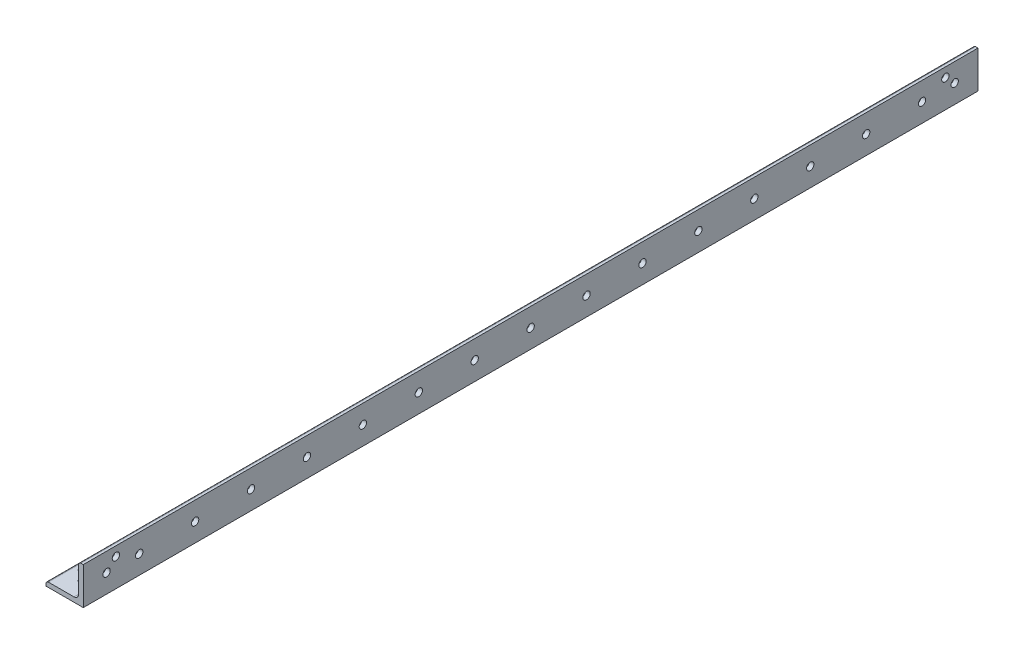
from build123d import *

# Parameters (mm, degrees)
BOSS_EXTRUDE1_DEPTH = 304.8
SKETCH3_R           = 2.5
CUT_EXTRUDE2_DEPTH  = 254
SKETCH8_R           = 2.5
CUT_EXTRUDE4_DEPTH  = 254
SKETCH9_R           = 2.25
CUT_EXTRUDE5_DEPTH  = 25.4


with BuildPart() as part:
    # Sketch2 → Boss-Extrude1 (new, symmetric)
    with BuildSketch(Plane.XY):
        with BuildLine():
            Line((-12.7, -12.7), (12.7, -12.7))
            Line((12.7, -12.7), (12.7, 12.7))
            Line((12.7, 12.7), (11.1125, 12.7))
            ThreePointArc((11.1125, 12.7), (9.989967985, 12.235032015), (9.525, 11.1125))
            Line((9.525, 11.1125), (9.525, -6.35))
            ThreePointArc((9.525, -6.35), (8.59506403, -8.59506403), (6.35, -9.525))
            Line((6.35, -9.525), (-11.1125, -9.525))
            ThreePointArc((-11.1125, -9.525), (-12.235032015, -9.989967985), (-12.7, -11.1125))
            Line((-12.7, -11.1125), (-12.7, -12.7))
        make_face()
    extrude(amount=BOSS_EXTRUDE1_DEPTH, both=True)

    # Sketch3 → Cut-Extrude2 (cut)
    with BuildSketch(Plane(origin=(0, 0, 0), x_dir=(1, 0, 0), z_dir=(0, 1, 0))):
        with Locations(Location((-6.35, 285.75, 0), (0, 0, 270))):
            Circle(SKETCH3_R)
        with Locations(Location((0, 292.1, 0), (0, 0, 270))):
            Circle(SKETCH3_R)
        with Locations(Location((0, 266.7, 0), (0, 0, 270))):
            Circle(SKETCH3_R)
        with Locations(Location((0, 228.6, 0), (0, 0, 270))):
            Circle(SKETCH3_R)
        with Locations(Location((0, 190.5, 0), (0, 0, 270))):
            Circle(SKETCH3_R)
        with Locations(Location((0, 152.4, 0), (0, 0, 270))):
            Circle(SKETCH3_R)
        with Locations(Location((0, 114.3, 0), (0, 0, 270))):
            Circle(SKETCH3_R)
        with Locations(Location((0, 76.2, 0), (0, 0, 270))):
            Circle(SKETCH3_R)
        with Locations(Location((0, 38.1, 0), (0, 0, 270))):
            Circle(SKETCH3_R)
        with Locations(Location((0, 0, 0), (0, 0, 270))):
            Circle(SKETCH3_R)
        with Locations(Location((0, -38.1, 0), (0, 0, 270))):
            Circle(SKETCH3_R)
        with Locations(Location((0, -76.2, 0), (0, 0, 270))):
            Circle(SKETCH3_R)
        with Locations(Location((0, -114.3, 0), (0, 0, 270))):
            Circle(SKETCH3_R)
        with Locations(Location((0, -292.1, 0), (0, 0, 270))):
            Circle(SKETCH3_R)
        with Locations(Location((-6.35, -285.75, 0), (0, 0, 270))):
            Circle(SKETCH3_R)
        with Locations(Location((0, -152.4, 0), (0, 0, 270))):
            Circle(SKETCH3_R)
        with Locations(Location((0, -190.5, 0), (0, 0, 270))):
            Circle(SKETCH3_R)
        with Locations(Location((0, -228.6, 0), (0, 0, 270))):
            Circle(SKETCH3_R)
        with Locations(Location((0, -266.7, 0), (0, 0, 270))):
            Circle(SKETCH3_R)
    extrude(amount=-CUT_EXTRUDE2_DEPTH, mode=Mode.SUBTRACT)

    # Sketch8 → Cut-Extrude4 (cut)
    with BuildSketch(Plane(origin=(12.7, 0, -12.7), x_dir=(0, 0, 1), z_dir=(-1, 0, 0))):
        with Locations(Location((295.275, 6.35, 0), (0, 0, 90))):
            Circle(SKETCH8_R)
        with Locations(Location((301.625, 0, 0), (0, 0, 90))):
            Circle(SKETCH8_R)
        with Locations(Location((279.4, 0, 0), (0, 0, 90))):
            Circle(SKETCH8_R)
        with Locations(Location((241.3, 0, 0), (0, 0, 90))):
            Circle(SKETCH8_R)
        with Locations(Location((203.2, 0, 0), (0, 0, 90))):
            Circle(SKETCH8_R)
        with Locations(Location((165.1, 0, 0), (0, 0, 90))):
            Circle(SKETCH8_R)
        with Locations(Location((127, 0, 0), (0, 0, 90))):
            Circle(SKETCH8_R)
        with Locations(Location((88.9, 0, 0), (0, 0, 90))):
            Circle(SKETCH8_R)
        with Locations(Location((50.8, 0, 0), (0, 0, 90))):
            Circle(SKETCH8_R)
        with Locations(Location((12.7, 0, 0), (0, 0, 90))):
            Circle(SKETCH8_R)
        with Locations(Location((-25.4, 0, 0), (0, 0, 90))):
            Circle(SKETCH8_R)
        with Locations(Location((-63.5, 0, 0), (0, 0, 90))):
            Circle(SKETCH8_R)
        with Locations(Location((-101.6, 0, 0), (0, 0, 90))):
            Circle(SKETCH8_R)
        with Locations(Location((-276.225, 0, 0), (0, 0, 90))):
            Circle(SKETCH8_R)
        with Locations(Location((-269.875, 6.35, 0), (0, 0, 90))):
            Circle(SKETCH8_R)
        with Locations(Location((-139.7, 0, 0), (0, 0, 90))):
            Circle(SKETCH8_R)
        with Locations(Location((-177.8, 0, 0), (0, 0, 90))):
            Circle(SKETCH8_R)
        with Locations(Location((-215.9, 0, 0), (0, 0, 90))):
            Circle(SKETCH8_R)
        with Locations(Location((-254, 0, 0), (0, 0, 90))):
            Circle(SKETCH8_R)
    extrude(amount=CUT_EXTRUDE4_DEPTH, mode=Mode.SUBTRACT)

    # Sketch9 → Cut-Extrude5 (cut)
    with BuildSketch(Plane(origin=(0, -12.7, 0), x_dir=(0, 0, -1), z_dir=(0, 1, 0))):
        with Locations(Location((-16, 0, 0), (0, 0, 270))):
            Circle(SKETCH9_R)
        with Locations(Location((16, 0, 0), (0, 0, 270))):
            Circle(SKETCH9_R)
    extrude(amount=CUT_EXTRUDE5_DEPTH, mode=Mode.SUBTRACT)


solid = part.part
